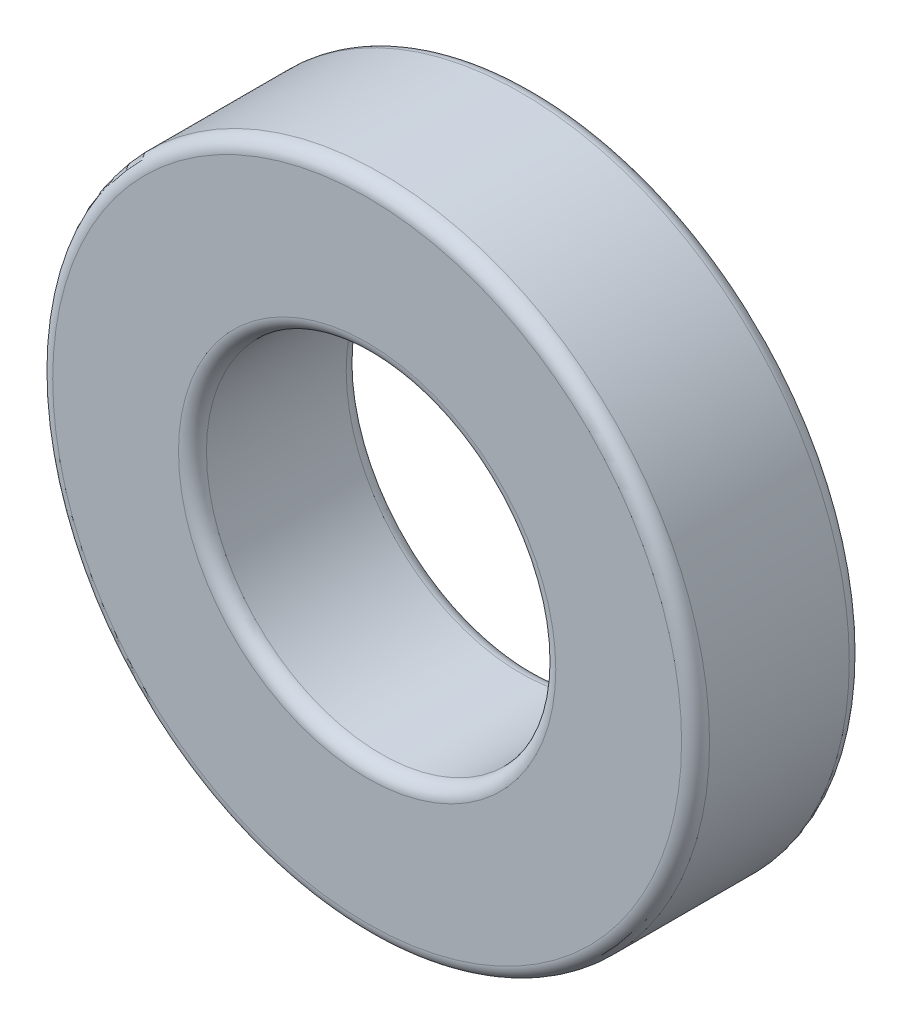
from build123d import *

# Parameters (mm, degrees)
SKETCH1_R           = 23.5
SKETCH1_R_2         = 12.5
BOSS_EXTRUDE1_DEPTH = 12
FILLET1_R           = 1


with BuildPart() as part:
    # Sketch1 → Boss-Extrude1 (new body)
    with BuildSketch(Plane.XY):
        Circle(SKETCH1_R)
        Circle(SKETCH1_R_2, mode=Mode.SUBTRACT)
    extrude(amount=BOSS_EXTRUDE1_DEPTH)

    # Fillet1
    fillet1_edges = [part.edges().sort_by_distance(p)[0] for p in [
        (-23.5, 0, 0),
        (-23.5, 0, 12),
        (-12.5, 0, 0),
        (-12.5, 0, 12),
    ]]
    fillet(fillet1_edges, radius=FILLET1_R)


solid = part.part
